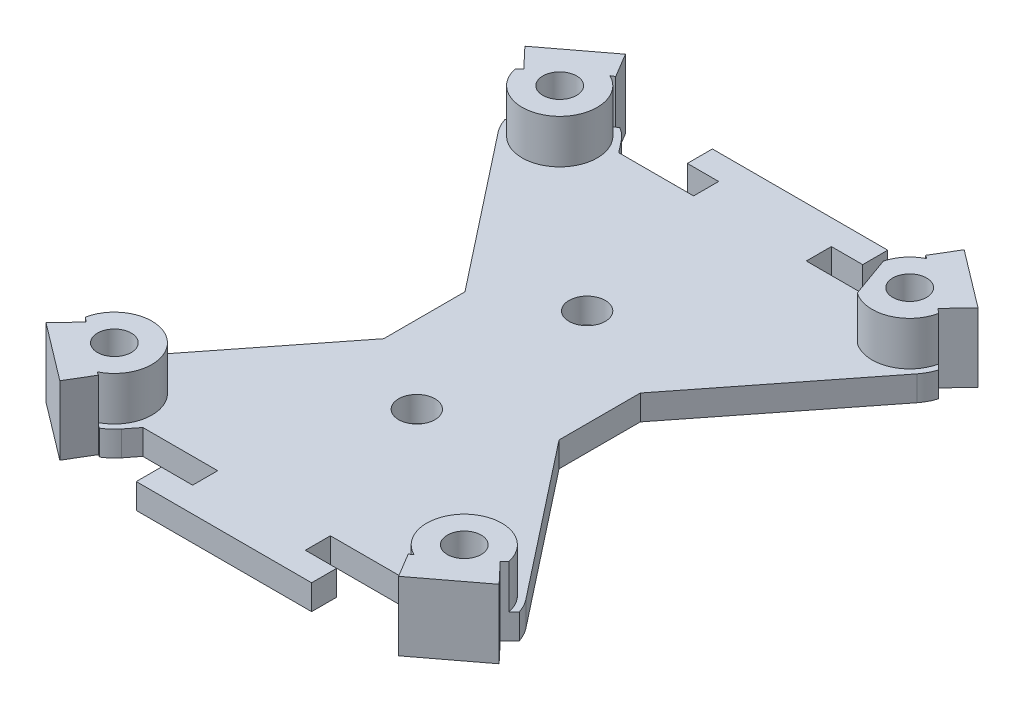
from build123d import *

# Parameters (mm, degrees)
SKETCH1_R               = 24.07
BOSS_EXTRUDE1_DEPTH     = 2
BOSS_EXTRUDE2_DEPTH     = 5.5
BOSS_EXTRUDE5_REACH     = 36.482
SKETCH2_R               = 3
SKETCH1_5_R             = 34.31362745
CUT_EXTRUDE3_DEPTH      = 35.48158639
CUT_EXTRUDE3_DEPTH_BACK = 35.48158639
M2_5_CLEARANCE_HOLE1_D  = 2.7
CUT_EXTRUDE4_DEPTH      = 35.48158639
SKETCH10_R              = 1.45
CUT_EXTRUDE6_DEPTH      = 30.773984948
CUT_EXTRUDE7_DEPTH      = 3.5


with BuildPart() as part:
    # Sketch1 → Boss-Extrude1 (new body)
    with BuildSketch(Plane(origin=(0, 0, 0), x_dir=(1, 0, 0), z_dir=(0, 1, 0))):
        with Locations(Location((0, 0, 0), (0, 0, 270))):
            Circle(SKETCH1_R)
    extrude(amount=BOSS_EXTRUDE1_DEPTH)

    # Sketch1_3 → Boss-Extrude2 (add)
    with BuildSketch(Plane(origin=(0, 0, 0), x_dir=(1, 0, 0), z_dir=(0, 1, 0))):
        with BuildLine():
            ThreePointArc((12.366915807, 20.650043424), (14.541516735, 19.180959075), (16.543257949, 17.483864459))
            Line((16.543257949, 17.483864459), (18.089781085, 19.118318867))
            Line((18.089781085, 19.118318867), (13.523019488, 22.580483607))
            Line((13.523019488, 22.580483607), (12.366915807, 20.650043424))
        make_face()
        with BuildLine():
            ThreePointArc((16.543257949, -17.483864459), (14.541516735, -19.180959075), (12.366915807, -20.650043424))
            Line((12.366915807, -20.650043424), (13.523019488, -22.580483607))
            Line((13.523019488, -22.580483607), (18.089781085, -19.118318867))
            Line((18.089781085, -19.118318867), (16.543257949, -17.483864459))
        make_face()
        with BuildLine():
            ThreePointArc((-16.543257949, 17.483864459), (-14.541516735, 19.180959075), (-12.366915807, 20.650043424))
            Line((-12.366915807, 20.650043424), (-13.523019488, 22.580483607))
            Line((-13.523019488, 22.580483607), (-18.089781085, 19.118318867))
            Line((-18.089781085, 19.118318867), (-16.543257949, 17.483864459))
        make_face()
        with BuildLine():
            ThreePointArc((-12.366915807, -20.650043424), (-14.541516735, -19.180959075), (-16.543257949, -17.483864459))
            Line((-16.543257949, -17.483864459), (-18.089781085, -19.118318867))
            Line((-18.089781085, -19.118318867), (-13.523019488, -22.580483607))
            Line((-13.523019488, -22.580483607), (-12.366915807, -20.650043424))
        make_face()
    extrude(amount=BOSS_EXTRUDE2_DEPTH)

    # Boss-Extrude5: up to this face of the body (flat: up to its plane)
    boss_extrude5_end = Plane(part.part.faces().sort_by_distance((15.168468653, 5.5, 20.00793877))[0])
    # Sketch2 → Boss-Extrude5 (add, up to the picked face)
    with BuildSketch(Plane(origin=(0, 0, 0), x_dir=(1, 0, 0), z_dir=(0, 1, 0)), mode=Mode.PRIVATE) as boss_extrude5_sk1:
        with Locations((13.97, 17.78)):
            Circle(SKETCH2_R)
    boss_extrude5_tool1 = split(extrude(boss_extrude5_sk1.sketch, amount=BOSS_EXTRUDE5_REACH, mode=Mode.PRIVATE), bisect_by=boss_extrude5_end, keep=Keep.BOTH, mode=Mode.PRIVATE)
    # Sketch2 → Boss-Extrude5 (add, up to the picked face)
    with BuildSketch(Plane(origin=(0, 0, 0), x_dir=(1, 0, 0), z_dir=(0, 1, 0)), mode=Mode.PRIVATE) as boss_extrude5_sk2:
        with Locations((13.97, -17.78)):
            Circle(SKETCH2_R)
    boss_extrude5_tool2 = split(extrude(boss_extrude5_sk2.sketch, amount=BOSS_EXTRUDE5_REACH, mode=Mode.PRIVATE), bisect_by=boss_extrude5_end, keep=Keep.BOTH, mode=Mode.PRIVATE)
    # Sketch2 → Boss-Extrude5 (add, up to the picked face)
    with BuildSketch(Plane(origin=(0, 0, 0), x_dir=(1, 0, 0), z_dir=(0, 1, 0)), mode=Mode.PRIVATE) as boss_extrude5_sk3:
        with Locations((-13.97, -17.78)):
            Circle(SKETCH2_R)
    boss_extrude5_tool3 = split(extrude(boss_extrude5_sk3.sketch, amount=BOSS_EXTRUDE5_REACH, mode=Mode.PRIVATE), bisect_by=boss_extrude5_end, keep=Keep.BOTH, mode=Mode.PRIVATE)
    # Sketch2 → Boss-Extrude5 (add, up to the picked face)
    with BuildSketch(Plane(origin=(0, 0, 0), x_dir=(1, 0, 0), z_dir=(0, 1, 0)), mode=Mode.PRIVATE) as boss_extrude5_sk4:
        with Locations((-13.97, 17.78)):
            Circle(SKETCH2_R)
    boss_extrude5_tool4 = split(extrude(boss_extrude5_sk4.sketch, amount=BOSS_EXTRUDE5_REACH, mode=Mode.PRIVATE), bisect_by=boss_extrude5_end, keep=Keep.BOTH, mode=Mode.PRIVATE)
    add(boss_extrude5_tool1.solids().sort_by(Axis((13.97, 0, -17.78), (0, 1, 0)))[0])
    add(boss_extrude5_tool2.solids().sort_by(Axis((13.97, 0, 17.78), (0, 1, 0)))[0])
    add(boss_extrude5_tool3.solids().sort_by(Axis((-13.97, 0, 17.78), (0, 1, 0)))[0])
    add(boss_extrude5_tool4.solids().sort_by(Axis((-13.97, 0, -17.78), (0, 1, 0)))[0])

    # Sketch1_5 → Cut-Extrude3 (cut, two sides)
    with BuildSketch(Plane(origin=(0, 0, 0), x_dir=(1, 0, 0), z_dir=(0, 1, 0))) as cut_extrude3_sk:
        Circle(SKETCH1_5_R)
        with BuildLine():
            Line((18.089781085, 19.118318867), (16.543257949, 17.483864459))
            ThreePointArc((16.543257949, 17.483864459), (22.108382108, 9.517580605), (24.07, 0))
            ThreePointArc((24.07, 0), (22.108382108, -9.517580605), (16.543257949, -17.483864459))
            Line((16.543257949, -17.483864459), (18.089781085, -19.118318867))
            Line((18.089781085, -19.118318867), (13.523019488, -22.580483607))
            Line((13.523019488, -22.580483607), (12.366915807, -20.650043424))
            ThreePointArc((12.366915807, -20.650043424), (0, -24.07), (-12.366915807, -20.650043424))
            Line((-12.366915807, -20.650043424), (-13.523019488, -22.580483607))
            Line((-13.523019488, -22.580483607), (-18.089781085, -19.118318867))
            Line((-18.089781085, -19.118318867), (-16.543257949, -17.483864459))
            ThreePointArc((-16.543257949, -17.483864459), (-24.07, 0), (-16.543257949, 17.483864459))
            Line((-16.543257949, 17.483864459), (-18.089781085, 19.118318867))
            Line((-18.089781085, 19.118318867), (-13.523019488, 22.580483607))
            Line((-13.523019488, 22.580483607), (-12.366915807, 20.650043424))
            ThreePointArc((-12.366915807, 20.650043424), (0, 24.07), (12.366915807, 20.650043424))
            Line((12.366915807, 20.650043424), (13.523019488, 22.580483607))
            Line((13.523019488, 22.580483607), (18.089781085, 19.118318867))
        make_face(mode=Mode.SUBTRACT)
    extrude(amount=CUT_EXTRUDE3_DEPTH, mode=Mode.SUBTRACT)
    extrude(cut_extrude3_sk.sketch, amount=-CUT_EXTRUDE3_DEPTH_BACK, mode=Mode.SUBTRACT)

    # M2.5 Clearance Hole1 (through all)
    with Locations(Plane(origin=(0, 5.5, 0), x_dir=(1, 0, 0), z_dir=(0, 1, 0))):
        with Locations((-13.97, 17.78), (13.97, 17.78), (13.97, -17.78), (-13.97, -17.78)):
            Hole(M2_5_CLEARANCE_HOLE1_D / 2)

    # Sketch8 → Cut-Extrude4 (cut, through all)
    with BuildSketch(Plane.XZ):
        with BuildLine():
            ThreePointArc((-12.157407277, 20.77407876), (-11.650071144, 20.400673597), (-11.217885814, 19.942375432))
            Line((-11.217885814, 19.942375432), (-10.477447975, 19))
            Line((-10.477447975, 19), (-4.5, 19))
            Line((-4.5, 19), (-4.5, 21))
            Line((-4.5, 21), (-7, 21))
            Line((-7, 21), (-7, 23))
            Line((-7, 23), (7, 23))
            Line((7, 23), (7, 21))
            Line((7, 21), (4.5, 21))
            Line((4.5, 21), (4.5, 19))
            Line((4.5, 19), (10.477447975, 19))
            Line((10.477447975, 19), (11.217885814, 19.942375432))
            ThreePointArc((11.217885814, 19.942375432), (11.650071144, 20.400673597), (12.157407277, 20.77407876))
            ThreePointArc((12.157407277, 20.77407876), (0, 24.07), (-12.157407277, 20.77407876))
        make_face()
        with BuildLine():
            Line((7, 3.244024695), (7, -3.244024695))
            Line((7, -3.244024695), (16.722114186, -15.617624568))
            ThreePointArc((16.722114186, -15.617624568), (17.065148682, -16.145969817), (17.307920228, -16.727247155))
            ThreePointArc((17.307920228, -16.727247155), (24.07, 0), (17.307920228, 16.727247155))
            ThreePointArc((17.307920228, 16.727247155), (17.065148682, 16.145969817), (16.722114186, 15.617624568))
            Line((16.722114186, 15.617624568), (7, 3.244024695))
        make_face()
        with BuildLine():
            Line((-7, -3.244024695), (-7, 3.244024695))
            Line((-7, 3.244024695), (-16.722114186, 15.617624568))
            ThreePointArc((-16.722114186, 15.617624568), (-17.065148682, 16.145969817), (-17.307920228, 16.727247155))
            ThreePointArc((-17.307920228, 16.727247155), (-24.07, 0), (-17.307920228, -16.727247155))
            ThreePointArc((-17.307920228, -16.727247155), (-17.065148682, -16.145969817), (-16.722114186, -15.617624568))
            Line((-16.722114186, -15.617624568), (-7, -3.244024695))
        make_face()
        with BuildLine():
            Line((11.217885814, -19.942375432), (10.477447975, -19))
            Line((10.477447975, -19), (4.5, -19))
            Line((4.5, -19), (4.5, -21))
            Line((4.5, -21), (7, -21))
            Line((7, -21), (7, -23))
            Line((7, -23), (-7, -23))
            Line((-7, -23), (-7, -21))
            Line((-7, -21), (-4.5, -21))
            Line((-4.5, -21), (-4.5, -19))
            Line((-4.5, -19), (-10.477447975, -19))
            Line((-10.477447975, -19), (-11.217885814, -19.942375432))
            ThreePointArc((-11.217885814, -19.942375432), (-11.650071144, -20.400673597), (-12.157407277, -20.77407876))
            ThreePointArc((-12.157407277, -20.77407876), (0, -24.07), (12.157407277, -20.77407876))
            ThreePointArc((12.157407277, -20.77407876), (11.650071144, -20.400673597), (11.217885814, -19.942375432))
        make_face()
    extrude(amount=-CUT_EXTRUDE4_DEPTH, mode=Mode.SUBTRACT)

    # Sketch10 → Cut-Extrude6 (cut, through all)
    with BuildSketch(Plane(origin=(0, 0, 0), x_dir=(1, 0, 0), z_dir=(0, 1, 0))):
        with Locations(Location((-0.8, -6.8, 0), (0, 0, 270))):
            Circle(SKETCH10_R)
        with Locations(Location((-0.8, 6.8, 0), (0, 0, 270))):
            Circle(SKETCH10_R)
    extrude(amount=CUT_EXTRUDE6_DEPTH, mode=Mode.SUBTRACT)

    # Sketch11 → Cut-Extrude7 (cut)
    with BuildSketch(Plane(origin=(0, 5.5, 0), x_dir=(1, 0, 0), z_dir=(0, 1, 0))):
        Polygon((0, 0), (17.739781085, 0), (10.209781085, 21), (0, 21), align=None)
    extrude(amount=-CUT_EXTRUDE7_DEPTH, mode=Mode.SUBTRACT)


solid = part.part
